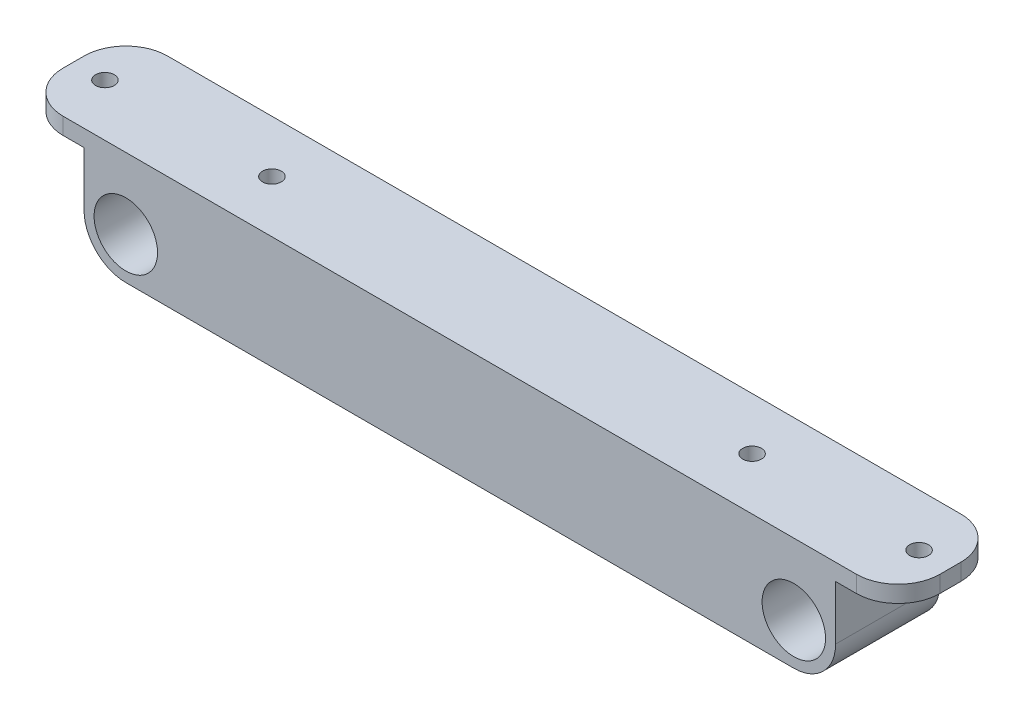
from build123d import *

# Parameters (mm, degrees)
SKETCH1_R            = 7.6
BOSS_EXTRUDE1_DEPTH  = 25
SKETCH2_W            = 30
SKETCH2_H            = 27
BOSS_EXTRUDE2_DEPTH  = 25
SKETCH3_R            = 7.6
BOSS_EXTRUDE3_DEPTH  = 2
CHAMFER1_SIZE        = 5
SKETCH5_W            = 25
SKETCH5_H            = 4
BOSS_EXTRUDE4_DEPTH  = 15
SKETCH6_R            = 2.25
CUT_EXTRUDE2_DEPTH   = 15
FILLET1_R            = 10
FILLET1_OF_MIRROR2_R = 10
SKETCH7_R            = 2.25
CUT_EXTRUDE3_DEPTH   = 15
CUT_EXTRUDE4_DEPTH   = 15


with BuildPart() as part:
    # Sketch1 → Boss-Extrude1 (new body)
    with BuildSketch(Plane.XY):
        with BuildLine():
            Line((-90, 0), (-90, 17))
            Line((-90, 17), (90, 17))
            Line((90, 17), (90, 0))
            ThreePointArc((90, 0), (80, -10), (70, 0))
            Line((70, 0), (70, 13))
            Line((70, 13), (-70, 13))
            Line((-70, 13), (-70, 0))
            ThreePointArc((-70, 0), (-80, -10), (-90, 0))
        make_face()
        with Locations((-80, 0)):
            Circle(SKETCH1_R, mode=Mode.SUBTRACT)
        with Locations((80, 0)):
            Circle(SKETCH1_R, mode=Mode.SUBTRACT)
    extrude(amount=BOSS_EXTRUDE1_DEPTH)

    # Sketch2 → Boss-Extrude2 (add)
    with BuildSketch(Plane(origin=(0, 0, 0), x_dir=(-1, 0, 0), z_dir=(0, 0, -1))):
        with Locations((-31, 3.5)):
            Rectangle(SKETCH2_W, SKETCH2_H)
    extrude(amount=-BOSS_EXTRUDE2_DEPTH)

    # Sketch3 → Boss-Extrude3 (add)
    with BuildSketch(Plane(origin=(0, 0, 0), x_dir=(-1, 0, 0), z_dir=(0, 0, -1))):
        with BuildLine():
            Line((80, -10), (-12, -10))
            Line((-12, -10), (-42, -10))
            Line((-42, -10), (-80, -10))
            ThreePointArc((-80, -10), (-87.071067812, -7.071067812), (-90, 0))
            Line((-90, 0), (-90, 17))
            Line((-90, 17), (90, 17))
            Line((90, 17), (90, 0))
            ThreePointArc((90, 0), (87.071067812, -7.071067812), (80, -10))
        make_face()
        with Locations((80, 0)):
            Circle(SKETCH3_R, mode=Mode.SUBTRACT)
        with Locations((-80, 0)):
            Circle(SKETCH3_R, mode=Mode.SUBTRACT)
    boss_extrude3 = extrude(amount=-BOSS_EXTRUDE3_DEPTH)

    # Mirror1: Boss-Extrude3 across plane
    add(boss_extrude3.mirror(Plane.XY.offset(12.5)))

    # Chamfer1
    chamfer1_edges = [part.edges().sort_by_distance(p)[0] for p in [
        (70, 13, 12.5),
        (-70, 13, 12.5),
    ]]
    chamfer(chamfer1_edges, length=CHAMFER1_SIZE)

    # Sketch5 → Boss-Extrude4 (add)
    with BuildSketch(Plane.ZY.offset(90)):
        with Locations((12.5, 15)):
            Rectangle(SKETCH5_W, SKETCH5_H)
    boss_extrude4 = extrude(amount=BOSS_EXTRUDE4_DEPTH)

    # Sketch6 → Cut-Extrude2 (cut)
    with BuildSketch(Plane(origin=(0, 13, 0), x_dir=(-1, 0, 0), z_dir=(0, -1, 0))):
        with Locations((97.5, -12.5)):
            Circle(SKETCH6_R)
    cut_extrude2 = extrude(amount=-CUT_EXTRUDE2_DEPTH, mode=Mode.SUBTRACT)

    # Fillet1
    fillet1_edges = [part.edges().sort_by_distance(p)[0] for p in [
        (-105, 15, 0),
        (-105, 15, 25),
    ]]
    fillet(fillet1_edges, radius=FILLET1_R)

    # Mirror2: Boss-Extrude4 across plane
    add(boss_extrude4.mirror(Plane(origin=(0, 0, 0), x_dir=(0, 0, 1), z_dir=(1, 0, 0))))

    # Fillet1 of Mirror2
    fillet1_of_mirror2_edges = [part.edges().sort_by_distance(p)[0] for p in [
        (105, 15, 0),
        (105, 15, 25),
    ]]
    fillet(fillet1_of_mirror2_edges, radius=FILLET1_OF_MIRROR2_R)

    # Mirror4: Cut-Extrude2 across plane
    add(cut_extrude2.mirror(Plane(origin=(0, 0, 0), x_dir=(0, 0, 1), z_dir=(1, 0, 0))), mode=Mode.SUBTRACT)

    # Sketch7 → Cut-Extrude3 (cut)
    with BuildSketch(Plane(origin=(0, 17, 0), x_dir=(1, 0, 0), z_dir=(0, 1, 0))):
        with Locations((-57.5, -12.5)):
            Circle(SKETCH7_R)
        with Locations((57.5, -12.5)):
            Circle(SKETCH7_R)
    extrude(amount=-CUT_EXTRUDE3_DEPTH, mode=Mode.SUBTRACT)

    # Sketch8 → Cut-Extrude4 (cut)
    with BuildSketch(Plane.XZ.offset(10)):
        with BuildLine():
            Line((21.95, 19), (20, 19))
            Line((20, 19), (20, 17.05))
            ThreePointArc((20, 17.05), (21.378858223, 17.621141777), (21.95, 19))
        make_face()
        with BuildLine():
            Line((20, 17.05), (20, 19))
            Line((20, 19), (21.95, 19))
            ThreePointArc((21.95, 19), (18.621141777, 20.378858223), (20, 17.05))
        make_face()
        with BuildLine():
            ThreePointArc((43.95, 19), (42, 20.95), (40.05, 19))
            Line((40.05, 19), (42, 19))
            Line((42, 19), (42, 17.05))
            ThreePointArc((42, 17.05), (43.378858223, 17.621141777), (43.95, 19))
        make_face()
        with BuildLine():
            Line((42, 19), (40.05, 19))
            ThreePointArc((40.05, 19), (40.621141777, 17.621141777), (42, 17.05))
            Line((42, 17.05), (42, 19))
        make_face()
        with BuildLine():
            ThreePointArc((42, 7.95), (40.621141777, 7.378858223), (40.05, 6))
            Line((40.05, 6), (42, 6))
            Line((42, 6), (42, 7.95))
        make_face()
        with BuildLine():
            Line((42, 6), (40.05, 6))
            ThreePointArc((40.05, 6), (42, 4.05), (43.95, 6))
            ThreePointArc((43.95, 6), (43.378858223, 7.378858223), (42, 7.95))
            Line((42, 7.95), (42, 6))
        make_face()
        with BuildLine():
            ThreePointArc((21.95, 6), (21.378858223, 7.378858223), (20, 7.95))
            Line((20, 7.95), (20, 6))
            Line((20, 6), (21.95, 6))
        make_face()
        with BuildLine():
            Line((20, 6), (20, 7.95))
            ThreePointArc((20, 7.95), (18.621141777, 4.621141777), (21.95, 6))
            Line((21.95, 6), (20, 6))
        make_face()
    extrude(amount=-CUT_EXTRUDE4_DEPTH, mode=Mode.SUBTRACT)


solid = part.part
